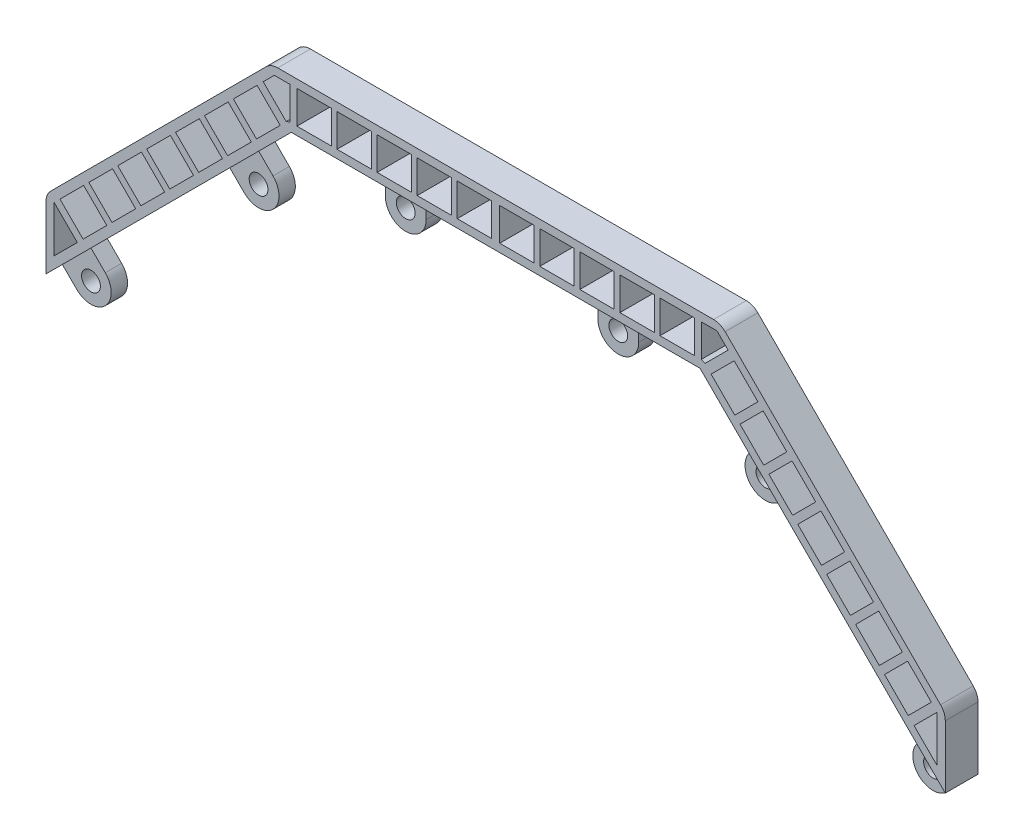
from build123d import *

# Parameters (mm, degrees)
SKETCH3_R                = 1.15
BOSS_EXTRUDE1_DEPTH      = 2
CUT_EXTRUDE4_DEPTH       = 2
FILLET1_R                = 2
CUT_EXTRUDE1_DEPTH       = 83.231380871
CUT_EXTRUDE2_DEPTH       = 83.158383626
LPATTERN1_COUNT          = 7
LPATTERN1_PITCH          = 5
SKETCH7_W                = 4.2
SKETCH7_H                = 4
CUT_EXTRUDE3_DEPTH       = 83.158383626
LPATTERN2_COUNT          = 5
LPATTERN2_PITCH          = 4.9
MIRROR1_COPY_1_DEPTH     = 83.158383626
MIRROR1_COPY_2_DEPTH     = 83.158383626
MIRROR1_COPY_3_DEPTH     = 83.158383626
MIRROR1_COPY_4_DEPTH     = 83.158383626
MIRROR1_COPY_5_DEPTH     = 83.158383626
MIRROR1_COPY_6_DEPTH     = 83.158383626
MIRROR1_COPY_7_SKETCH_W  = 4.2
MIRROR1_COPY_7_SKETCH_H  = 4
MIRROR1_COPY_7_DEPTH     = 83.158383626
MIRROR1_COPY_8_SKETCH_W  = 4.2
MIRROR1_COPY_8_SKETCH_H  = 4
MIRROR1_COPY_8_DEPTH     = 83.158383626
MIRROR1_COPY_9_SKETCH_W  = 4.2
MIRROR1_COPY_9_SKETCH_H  = 4
MIRROR1_COPY_9_DEPTH     = 83.158383626
MIRROR1_COPY_10_SKETCH_W = 4.2
MIRROR1_COPY_10_SKETCH_H = 4
MIRROR1_COPY_10_DEPTH    = 83.158383626
FILLET1_OF_MIRROR1_R     = 2


with BuildPart() as part:
    # Sketch3 → Boss-Extrude1 (new, symmetric)
    with BuildSketch(Plane.XY):
        with BuildLine():
            Line((-55, 25), (-53.25, 23.25))
            ThreePointArc((-53.25, 23.25), (-49.75, 23.25), (-49.75, 26.75))
            Line((-49.75, 26.75), (-51.5, 28.5))
            Line((-51.5, 28.5), (-34.517766953, 45.482233047))
            Line((-34.517766953, 45.482233047), (-32.767766953, 43.732233047))
            ThreePointArc((-32.767766953, 43.732233047), (-29.232233047, 43.732233047), (-29.232233047, 47.267766953))
            Line((-29.232233047, 47.267766953), (-30.982233047, 49.017766953))
            Line((-30.982233047, 49.017766953), (-25, 55))
            Line((-25, 55), (-15.5, 55))
            Line((-15.5, 55), (-15.5, 52))
            ThreePointArc((-15.5, 52), (-13, 49.5), (-10.5, 52))
            Line((-10.5, 52), (-10.5, 55))
            Line((-10.5, 55), (0, 55))
            Line((0, 55), (0, 61))
            Line((0, 61), (-27.485281374, 61))
            Line((-27.485281374, 61), (-55, 33.485281374))
            Line((-55, 33.485281374), (-55, 25))
        make_face()
        with Locations((-13, 52)):
            Circle(SKETCH3_R, mode=Mode.SUBTRACT)
        with Locations((-31, 45.5)):
            Circle(SKETCH3_R, mode=Mode.SUBTRACT)
        with Locations((-51.5, 25)):
            Circle(SKETCH3_R, mode=Mode.SUBTRACT)
    boss_extrude1 = extrude(amount=BOSS_EXTRUDE1_DEPTH, both=True)

    # Sketch8 → Cut-Extrude4 (cut)
    with BuildSketch(Plane.XY.offset(2)):
        with BuildLine():
            Line((-55, 25), (-51.5, 28.5))
            Line((-51.5, 28.5), (-49.75, 26.75))
            ThreePointArc((-49.75, 26.75), (-49.75, 23.25), (-53.25, 23.25))
            Line((-53.25, 23.25), (-55, 25))
        make_face()
        with BuildLine():
            Line((-34.517766953, 45.482233047), (-30.982233047, 49.017766953))
            Line((-30.982233047, 49.017766953), (-29.232233047, 47.267766953))
            ThreePointArc((-29.232233047, 47.267766953), (-29.232233047, 43.732233047), (-32.767766953, 43.732233047))
            Line((-32.767766953, 43.732233047), (-34.517766953, 45.482233047))
        make_face()
        with BuildLine():
            Line((-15.5, 55), (-10.5, 55))
            Line((-10.5, 55), (-10.5, 52))
            ThreePointArc((-10.5, 52), (-13, 49.5), (-15.5, 52))
            Line((-15.5, 52), (-15.5, 55))
        make_face()
    cut_extrude4 = extrude(amount=-CUT_EXTRUDE4_DEPTH, mode=Mode.SUBTRACT)

    # Fillet1
    fillet1_edges = [part.edges().sort_by_distance(p)[0] for p in [
        (-55, 33.485281374, 0),
        (-27.485281374, 61, 0),
    ]]
    fillet(fillet1_edges, radius=FILLET1_R)

    # Sketch5 → Cut-Extrude1 (cut, through all)
    with BuildSketch(Plane.XY.offset(2)):
        Polygon((-28.428256226, 58.642811585), (-27.071067812, 60), (-25.151713549, 60), (-25.151713549, 56.019550391), (-25.613653315, 55.828208674), align=None)
        Polygon((-54, 33.071067812), (-54, 27.414213562), (-51.171572875, 30.242640687), align=None)
    cut_extrude1 = extrude(amount=-CUT_EXTRUDE1_DEPTH, mode=Mode.SUBTRACT)

    # Sketch6 → Cut-Extrude2 (cut, symmetric)
    with BuildSketch(Plane.XY):
        Polygon((-53.292893219, 33.778174593), (-50.393755416, 36.677312396), (-47.565328291, 33.848885271), (-50.464466094, 30.949747468), align=None)
    cut_extrude2 = extrude(amount=CUT_EXTRUDE2_DEPTH, both=True, mode=Mode.SUBTRACT)

    # LPattern1: Cut-Extrude2 ×7
    with Locations(*[Vector(0.7071067811865472, 0.7071067811865478, 0) * (i * LPATTERN1_PITCH) for i in range(1, LPATTERN1_COUNT)]):
        add(cut_extrude2, mode=Mode.SUBTRACT)

    # Sketch7 → Cut-Extrude3 (cut, symmetric)
    with BuildSketch(Plane.XY):
        with Locations((-2.6, 58)):
            Rectangle(SKETCH7_W, SKETCH7_H)
    cut_extrude3 = extrude(amount=CUT_EXTRUDE3_DEPTH, both=True, mode=Mode.SUBTRACT)

    # LPattern2: Cut-Extrude3 ×5
    with Locations(*[(-i * LPATTERN2_PITCH, 0, 0) for i in range(1, LPATTERN2_COUNT)]):
        add(cut_extrude3, mode=Mode.SUBTRACT)

    # Mirror1: Boss-Extrude1, Cut-Extrude4, Cut-Extrude1, Cut-Extrude2, Cut-Extrude3 across plane
    add(boss_extrude1.mirror(Plane(origin=(0, 55, 2), x_dir=(0, 0, 1), z_dir=(-1, 0, 0))))
    add(cut_extrude4.mirror(Plane(origin=(0, 55, 2), x_dir=(0, 0, 1), z_dir=(-1, 0, 0))), mode=Mode.SUBTRACT)
    add(cut_extrude1.mirror(Plane(origin=(0, 55, 2), x_dir=(0, 0, 1), z_dir=(-1, 0, 0))), mode=Mode.SUBTRACT)
    add(cut_extrude2.mirror(Plane(origin=(0, 55, 2), x_dir=(0, 0, 1), z_dir=(-1, 0, 0))), mode=Mode.SUBTRACT)
    add(cut_extrude3.mirror(Plane(origin=(0, 55, 2), x_dir=(0, 0, 1), z_dir=(-1, 0, 0))), mode=Mode.SUBTRACT)

    # Mirror1 copy 1 sketch → Mirror1 copy 1 (cut, symmetric)
    with BuildSketch(Plane(origin=(-3.535533906, 3.535533906, 0), x_dir=(-1, 0, 0), z_dir=(0, 0, 1))):
        Polygon((-53.292893219, -33.778174593), (-50.393755416, -36.677312396), (-47.565328291, -33.848885271), (-50.464466094, -30.949747468), align=None)
    extrude(amount=MIRROR1_COPY_1_DEPTH, both=True, mode=Mode.SUBTRACT)

    # Mirror1 copy 2 sketch → Mirror1 copy 2 (cut, symmetric)
    with BuildSketch(Plane(origin=(-7.071067812, 7.071067812, 0), x_dir=(-1, 0, 0), z_dir=(0, 0, 1))):
        Polygon((-53.292893219, -33.778174593), (-50.393755416, -36.677312396), (-47.565328291, -33.848885271), (-50.464466094, -30.949747468), align=None)
    extrude(amount=MIRROR1_COPY_2_DEPTH, both=True, mode=Mode.SUBTRACT)

    # Mirror1 copy 3 sketch → Mirror1 copy 3 (cut, symmetric)
    with BuildSketch(Plane(origin=(-10.606601718, 10.606601718, 0), x_dir=(-1, 0, 0), z_dir=(0, 0, 1))):
        Polygon((-53.292893219, -33.778174593), (-50.393755416, -36.677312396), (-47.565328291, -33.848885271), (-50.464466094, -30.949747468), align=None)
    extrude(amount=MIRROR1_COPY_3_DEPTH, both=True, mode=Mode.SUBTRACT)

    # Mirror1 copy 4 sketch → Mirror1 copy 4 (cut, symmetric)
    with BuildSketch(Plane(origin=(-14.142135624, 14.142135624, 0), x_dir=(-1, 0, 0), z_dir=(0, 0, 1))):
        Polygon((-53.292893219, -33.778174593), (-50.393755416, -36.677312396), (-47.565328291, -33.848885271), (-50.464466094, -30.949747468), align=None)
    extrude(amount=MIRROR1_COPY_4_DEPTH, both=True, mode=Mode.SUBTRACT)

    # Mirror1 copy 5 sketch → Mirror1 copy 5 (cut, symmetric)
    with BuildSketch(Plane(origin=(-17.67766953, 17.67766953, 0), x_dir=(-1, 0, 0), z_dir=(0, 0, 1))):
        Polygon((-53.292893219, -33.778174593), (-50.393755416, -36.677312396), (-47.565328291, -33.848885271), (-50.464466094, -30.949747468), align=None)
    extrude(amount=MIRROR1_COPY_5_DEPTH, both=True, mode=Mode.SUBTRACT)

    # Mirror1 copy 6 sketch → Mirror1 copy 6 (cut, symmetric)
    with BuildSketch(Plane(origin=(-21.213203436, 21.213203436, 0), x_dir=(-1, 0, 0), z_dir=(0, 0, 1))):
        Polygon((-53.292893219, -33.778174593), (-50.393755416, -36.677312396), (-47.565328291, -33.848885271), (-50.464466094, -30.949747468), align=None)
    extrude(amount=MIRROR1_COPY_6_DEPTH, both=True, mode=Mode.SUBTRACT)

    # Mirror1 copy 7 sketch → Mirror1 copy 7 (cut, symmetric)
    with BuildSketch(Plane(origin=(4.9, 0, 0), x_dir=(-1, 0, 0), z_dir=(0, 0, 1))):
        with Locations((-2.6, -58)):
            Rectangle(MIRROR1_COPY_7_SKETCH_W, MIRROR1_COPY_7_SKETCH_H)
    extrude(amount=MIRROR1_COPY_7_DEPTH, both=True, mode=Mode.SUBTRACT)

    # Mirror1 copy 8 sketch → Mirror1 copy 8 (cut, symmetric)
    with BuildSketch(Plane(origin=(9.8, 0, 0), x_dir=(-1, 0, 0), z_dir=(0, 0, 1))):
        with Locations((-2.6, -58)):
            Rectangle(MIRROR1_COPY_8_SKETCH_W, MIRROR1_COPY_8_SKETCH_H)
    extrude(amount=MIRROR1_COPY_8_DEPTH, both=True, mode=Mode.SUBTRACT)

    # Mirror1 copy 9 sketch → Mirror1 copy 9 (cut, symmetric)
    with BuildSketch(Plane(origin=(14.7, 0, 0), x_dir=(-1, 0, 0), z_dir=(0, 0, 1))):
        with Locations((-2.6, -58)):
            Rectangle(MIRROR1_COPY_9_SKETCH_W, MIRROR1_COPY_9_SKETCH_H)
    extrude(amount=MIRROR1_COPY_9_DEPTH, both=True, mode=Mode.SUBTRACT)

    # Mirror1 copy 10 sketch → Mirror1 copy 10 (cut, symmetric)
    with BuildSketch(Plane(origin=(19.6, 0, 0), x_dir=(-1, 0, 0), z_dir=(0, 0, 1))):
        with Locations((-2.6, -58)):
            Rectangle(MIRROR1_COPY_10_SKETCH_W, MIRROR1_COPY_10_SKETCH_H)
    extrude(amount=MIRROR1_COPY_10_DEPTH, both=True, mode=Mode.SUBTRACT)

    # Fillet1 of Mirror1
    fillet1_of_mirror1_edges = [part.edges().sort_by_distance(p)[0] for p in [
        (55, 33.485281374, 0),
        (27.485281374, 61, 0),
    ]]
    fillet(fillet1_of_mirror1_edges, radius=FILLET1_OF_MIRROR1_R)


solid = part.part
